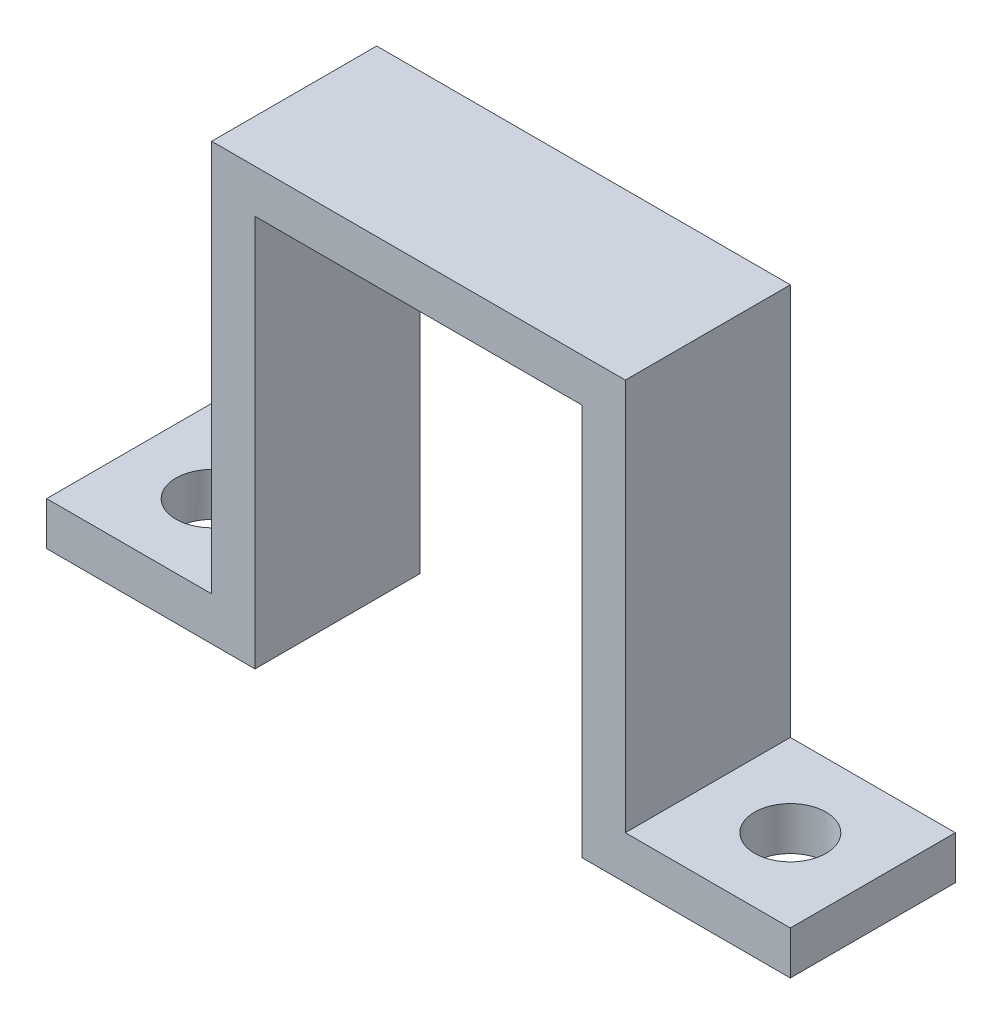
from build123d import *

# Parameters (mm, degrees)
BOSS_EXTRUDE1_DEPTH = 3.81
SKETCH2_R           = 1.65
CUT_EXTRUDE1_DEPTH  = 2


with BuildPart() as part:
    # Sketch1 → Boss-Extrude1 (new body, symmetric)
    with BuildSketch(Plane.XY):
        Polygon((9.55, 0), (-9.55, 0), (-9.55, -18.1), (-17.17, -18.1), (-17.17, -20.1), (-7.55, -20.1), (-7.55, -2), (7.55, -2), (7.55, -20.1), (17.17, -20.1), (17.17, -18.1), (9.55, -18.1), align=None)
    extrude(amount=BOSS_EXTRUDE1_DEPTH, both=True)

    # Sketch2 → Cut-Extrude1 (cut)
    with BuildSketch(Plane(origin=(0, -18.1, 0), x_dir=(1, 0, 0), z_dir=(0, 1, 0))):
        with Locations((-13.36, 0)):
            Circle(SKETCH2_R)
    cut_extrude1 = extrude(amount=-CUT_EXTRUDE1_DEPTH, mode=Mode.SUBTRACT)

    # Mirror1: Cut-Extrude1 across plane
    add(cut_extrude1.mirror(Plane(origin=(0, 0, 0), x_dir=(0, 0, 1), z_dir=(1, 0, 0))), mode=Mode.SUBTRACT)


solid = part.part
